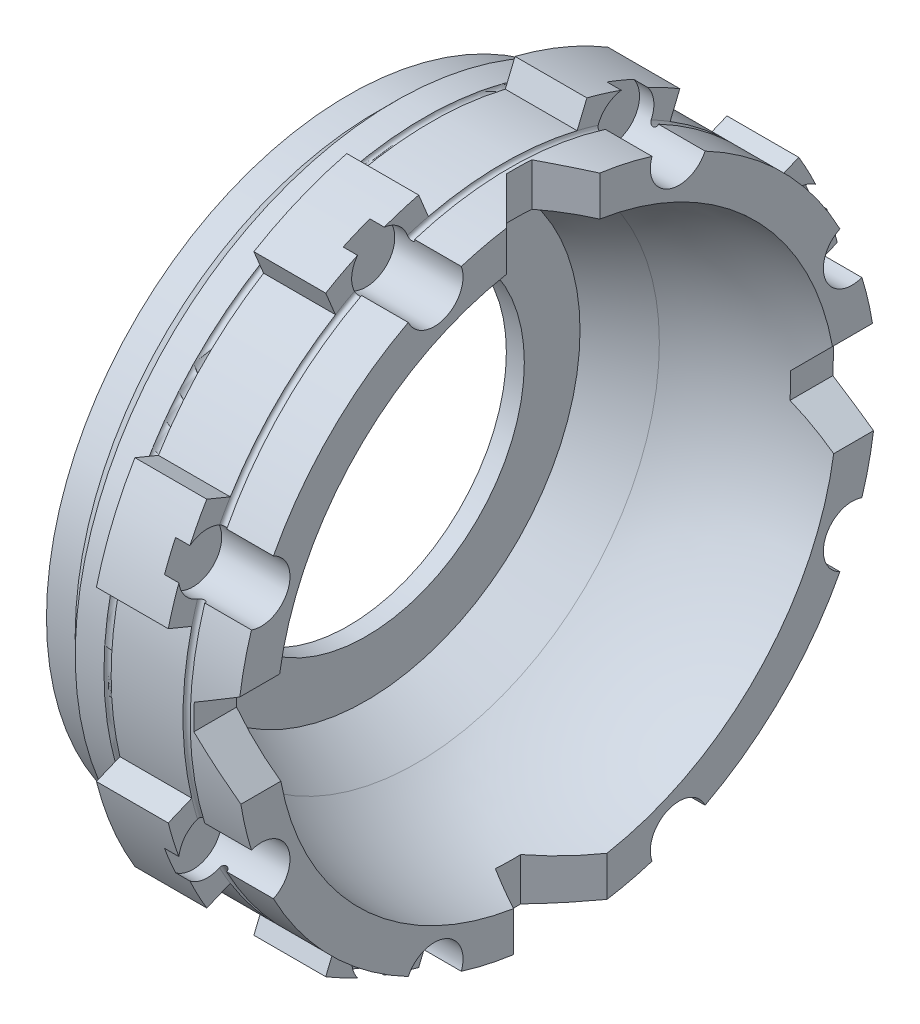
from build123d import *

# Parameters (mm, degrees)
P_IDAT_VYSUNUT_M1_DEPTH  = 10
SKICA4_R                 = 4
ODEBRAT_VYSUNUT_M1_DEPTH = 9.5
KRUHOV_POLE1_COUNT       = 8
ODEBRAT_VYSUNUT_M2_DEPTH = 9.5
KRUHOV_POLE2_COUNT       = 4


with BuildPart() as part:
    # Skica1 → Rotovat1 (revolve)
    with BuildSketch(Plane.XY):
        with BuildLine():
            Line((0, 42), (4, 42))
            Line((4, 42), (6.5, 44.5))
            Line((6.5, 44.5), (29, 44.5))
            Line((29, 44.5), (29, 39.016461137))
            ThreePointArc((29, 39.016461137), (18.906057241, 37.687568362), (9.5, 33.791451884))
            Line((9.5, 33.791451884), (2.5, 29.75))
            Line((2.5, 29.75), (2.5, 22))
            Line((2.5, 22), (0, 22))
            Line((0, 22), (0, 42))
        make_face()
    revolve(axis=Axis((0, 0, 0), (-1, 0, 0)))

    # Skica2 → Odebrat rotací1 (revolve, cut)
    with BuildSketch(Plane.XY):
        with BuildLine():
            Line((10.5, 44.5), (11.5, 44.5))
            ThreePointArc((11.5, 44.5), (11, 44), (10.5, 44.5))
        make_face()
        with BuildLine():
            Line((21.5, 44.5), (22.5, 44.5))
            ThreePointArc((22.5, 44.5), (22, 44), (21.5, 44.5))
        make_face()
    revolve(axis=Axis((0, 0, 0), (1, 0, 0)), mode=Mode.SUBTRACT)

    # Skica3 → Přidat vysunutím1 (add)
    with BuildSketch(Plane(origin=(21.5, 0, 0), x_dir=(0, 0, -1), z_dir=(1, 0, 0))):
        with BuildLine():
            Line((11.705270304, 46.550903827), (10.350245403, 43.279584334))
            ThreePointArc((10.350245403, 43.279584334), (17.02941274, 41.112639197), (23.284558858, 37.922016281))
            Line((23.284558858, 37.922016281), (24.639583759, 41.193335774))
            ThreePointArc((24.639583759, 41.193335774), (18.368804754, 44.346217561), (11.705270304, 46.550903827))
        make_face()
    p_idat_vysunut_m1 = extrude(amount=-P_IDAT_VYSUNUT_M1_DEPTH)

    # Skica4 → Odebrat vysunutím1 (cut)
    with BuildSketch(Plane(origin=(29, 0, 0), x_dir=(0, 0, -1), z_dir=(1, 0, 0))):
        with Locations((17.02941274, 41.112639197)):
            Circle(SKICA4_R)
    odebrat_vysunut_m1 = extrude(amount=-ODEBRAT_VYSUNUT_M1_DEPTH, mode=Mode.SUBTRACT)

    # Kruhové pole1: Přidat vysunutím1, Odebrat vysunutím1 ×8 about axis
    kruhov_pole1_axis = Axis((0, 0, 0), (1, 0, 0))
    for i in range(1, KRUHOV_POLE1_COUNT):
        add(p_idat_vysunut_m1.rotate(kruhov_pole1_axis, i * 360 / KRUHOV_POLE1_COUNT))
        add(odebrat_vysunut_m1.rotate(kruhov_pole1_axis, i * 360 / KRUHOV_POLE1_COUNT), mode=Mode.SUBTRACT)

    # Skica5 → Odebrat vysunutím2 (cut)
    with BuildSketch(Plane.XY.offset(44.5)):
        Polygon((29, 6), (29, -7), (23, -1), (23, 2.535898385), align=None)
    odebrat_vysunut_m2 = extrude(amount=-ODEBRAT_VYSUNUT_M2_DEPTH, mode=Mode.SUBTRACT)

    # Kruhové pole2: Odebrat vysunutím2 ×4 about axis
    kruhov_pole2_axis = Axis((0, 0, 0), (1, 0, 0))
    for i in range(1, KRUHOV_POLE2_COUNT):
        add(odebrat_vysunut_m2.rotate(kruhov_pole2_axis, i * 360 / KRUHOV_POLE2_COUNT), mode=Mode.SUBTRACT)


solid = part.part
